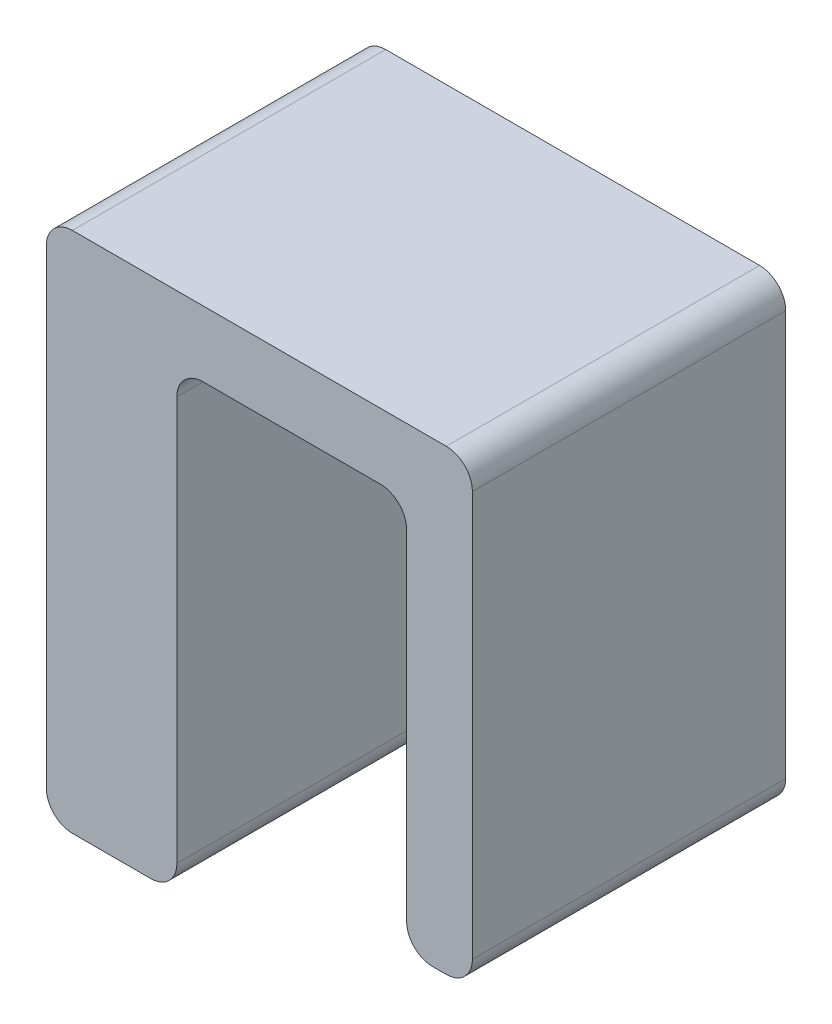
from build123d import *

# Parameters (mm, degrees)
BOSS_EXTRUDE1_DEPTH = 7.62
FILLET1_R           = 0.635


with BuildPart() as part:
    # Sketch1 → Boss-Extrude1 (new body)
    with BuildSketch(Plane.XY):
        Polygon((0, 0), (0, 12.7), (10.363, 12.7), (10.363, 1.575), (8.763, 1.575), (8.763, 11.1), (3.175, 11.1), (3.175, 0), align=None)
    extrude(amount=BOSS_EXTRUDE1_DEPTH)

    # Fillet1
    fillet1_edges = [part.edges().sort_by_distance(p)[0] for p in [
        (0, 0, 3.81),
        (0, 12.7, 3.81),
        (10.363, 12.7, 3.81),
        (10.363, 1.575, 3.81),
        (8.763, 1.575, 3.81),
        (8.763, 11.1, 3.81),
        (3.175, 11.1, 3.81),
        (3.175, 0, 3.81),
    ]]
    fillet(fillet1_edges, radius=FILLET1_R)


solid = part.part
